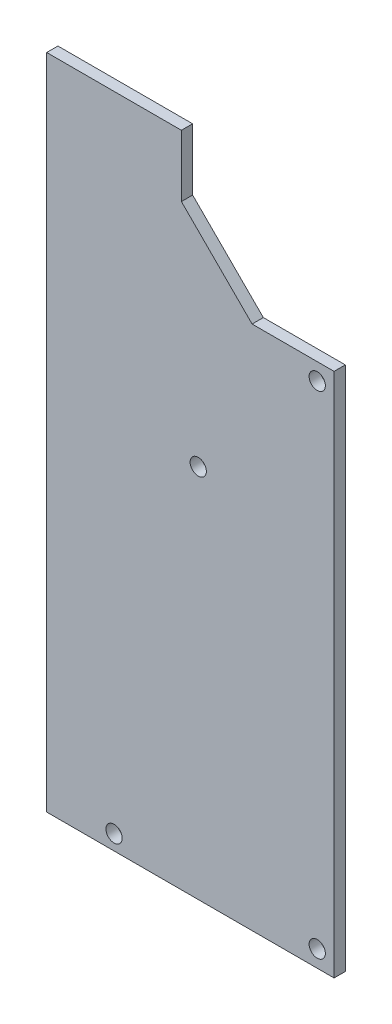
from build123d import *

# Parameters (mm, degrees)
SKETCH1_W                  = 19.05
SKETCH1_H                  = 88.9
BOSS_EXTRUDE1_DEPTH        = 1.5875
SKETCH4_W                  = 21.59
SKETCH4_H                  = 71.755
BOSS_EXTRUDE2_DEPTH        = 1.5875
CHAMFER1_SIZE              = 10
SKETCH5_W                  = 40.64
SKETCH5_H                  = 2.54
SKETCH5_W_2                = 19.05
SKETCH5_H_2                = 1.5875
BOSS_EXTRUDE3_DEPTH        = 1.5875
F_2_3_2_3_DIAMETER_HOLE1_D = 2.3


with BuildPart() as part:
    # Sketch1 → Boss-Extrude1 (new body)
    with BuildSketch(Plane.XY):
        with Locations((3.01625, 39.14175)):
            Rectangle(SKETCH1_W, SKETCH1_H)
    extrude(amount=BOSS_EXTRUDE1_DEPTH)

    # Sketch4 → Boss-Extrude2 (add, through all)
    with BuildSketch(Plane.XY.offset(1.5875)):
        with Locations((23.33625, 30.56925)):
            Rectangle(SKETCH4_W, SKETCH4_H)
    extrude(amount=-BOSS_EXTRUDE2_DEPTH)

    # Chamfer1
    chamfer1_edges = [part.edges().sort_by_distance(p)[0] for p in [
        (12.54125, 66.44675, 0.79375),
    ]]
    chamfer(chamfer1_edges, length=CHAMFER1_SIZE)

    # Sketch5 → Boss-Extrude3 (add, through all)
    with BuildSketch(Plane.XY.offset(1.5875)):
        with Locations((13.81125, -6.57825)):
            Rectangle(SKETCH5_W, SKETCH5_H)
        with Locations((3.01625, 84.3855)):
            Rectangle(SKETCH5_W_2, SKETCH5_H_2)
    extrude(amount=-BOSS_EXTRUDE3_DEPTH)

    # Ø2.3 (2.3) Diameter Hole1 (through all)
    with Locations(Plane.XY.offset(1.5875)):
        with Locations((14.9225, 45.1655), (31.75, 64.0655), (31.75, -5.467), (3.01625, -5.721)):
            Hole(F_2_3_2_3_DIAMETER_HOLE1_D / 2)


solid = part.part
